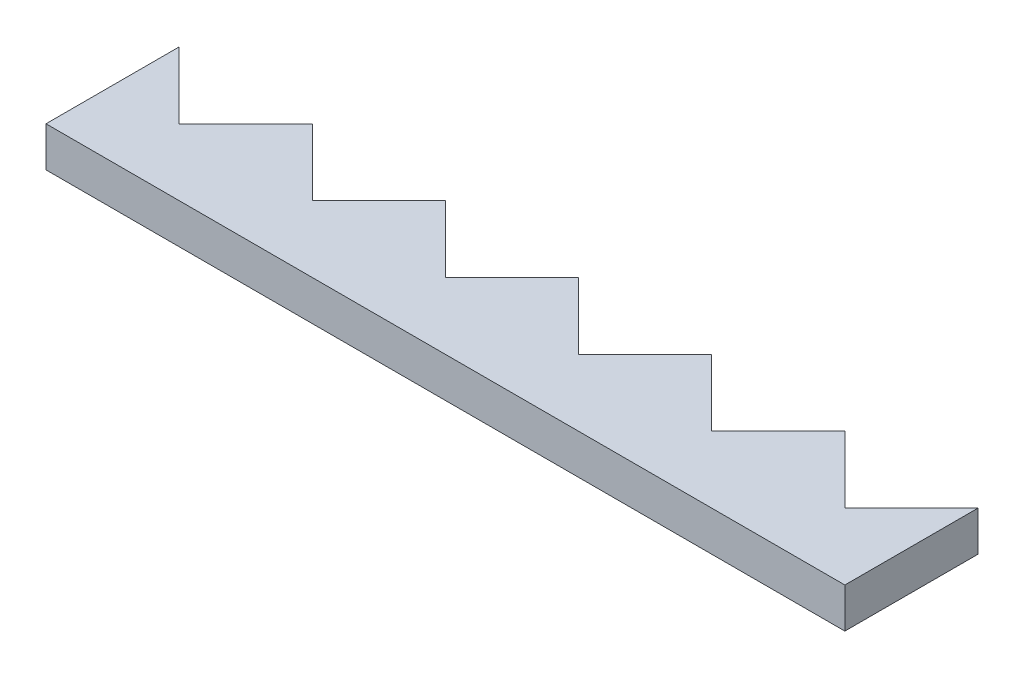
from build123d import *

# Parameters (mm, degrees)
BOSS_EXTRUDE1_DEPTH = 3


with BuildPart() as part:
    # Sketch1 → Boss-Extrude1 (new body)
    with BuildSketch(Plane(origin=(0, 0.330251497, 0), x_dir=(1, 0, 0), z_dir=(0, 1, 0))):
        Polygon((0, 0), (0, 10), (5, 5), (10, 10), (15, 5), (20, 10), (25, 5), (30, 10), (35, 5), (40, 10), (45, 5), (50, 10), (55, 5), (60, 10), (60, 0), align=None)
    extrude(amount=BOSS_EXTRUDE1_DEPTH)


solid = part.part
